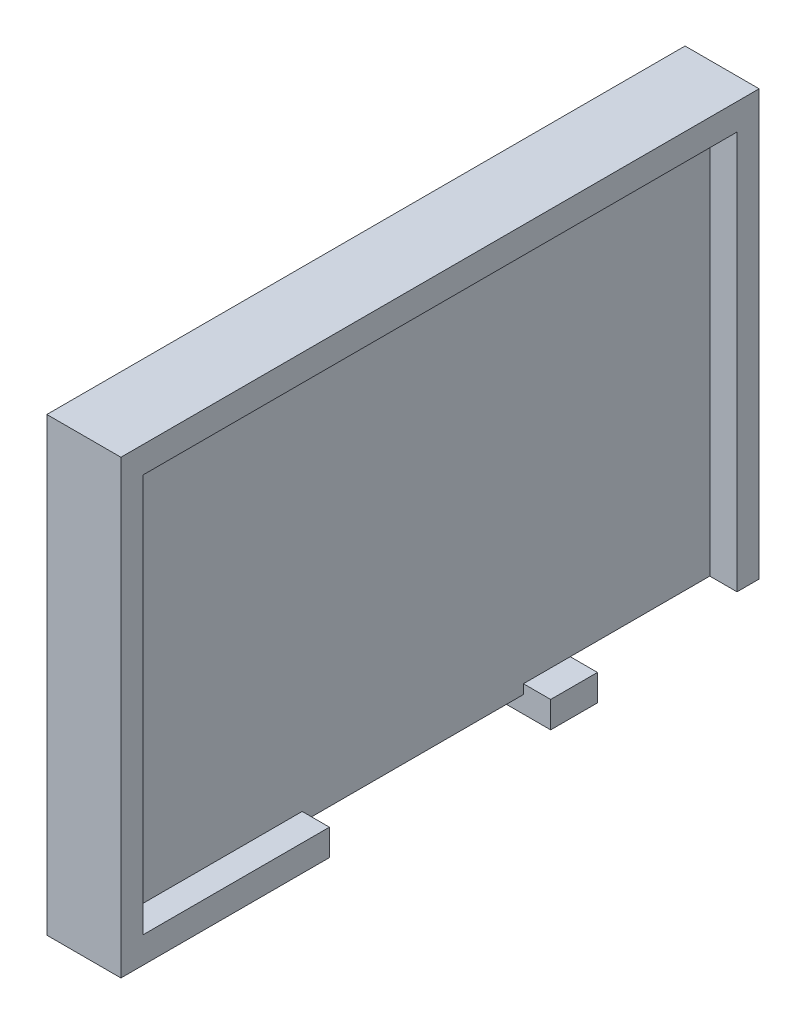
from build123d import *

# Parameters (mm, degrees)
SKETCH1_W           = 26.5
SKETCH1_H           = 37.5
BOSS_EXTRUDE1_DEPTH = 4.353
SKETCH2_W           = 23.4
SKETCH2_H           = 34.9
CUT_EXTRUDE1_DEPTH  = 1.6
SKETCH3_W           = 1.55
SKETCH3_H           = 13
CUT_EXTRUDE2_DEPTH  = 1.6
SKETCH4_W           = 2.753
SKETCH4_H           = 13
CUT_EXTRUDE3_DEPTH  = 1
SKETCH5_W           = 1.55
SKETCH5_H           = 9.5
CUT_EXTRUDE5_DEPTH  = 1.6
CUT_EXTRUDE6_DEPTH  = 9.5
SKETCH7_W           = 4.587747781
SKETCH7_H           = 26.668615153
SKETCH7_W_2         = 9.921470812
SKETCH7_H_2         = 17.49311959
CUT_EXTRUDE7_DEPTH  = 2
SKETCH8_W           = 1.6
SKETCH8_H           = 3.8
BOSS_EXTRUDE2_DEPTH = 1.6


with BuildPart() as part:
    # Sketch1 → Boss-Extrude1 (new body)
    with BuildSketch(Plane.YZ):
        with Locations((57.87, 107.93)):
            Rectangle(SKETCH1_W, SKETCH1_H)
    extrude(amount=BOSS_EXTRUDE1_DEPTH)

    # Sketch2 → Cut-Extrude1 (cut)
    with BuildSketch(Plane.YZ.offset(4.353)):
        with Locations((57.87, 107.93)):
            Rectangle(SKETCH2_W, SKETCH2_H)
    extrude(amount=-CUT_EXTRUDE1_DEPTH, mode=Mode.SUBTRACT)

    # Sketch3 → Cut-Extrude2 (cut)
    with BuildSketch(Plane.YZ.offset(4.353)):
        with Locations((45.395, 107.93)):
            Rectangle(SKETCH3_W, SKETCH3_H)
    extrude(amount=-CUT_EXTRUDE2_DEPTH, mode=Mode.SUBTRACT)

    # Sketch4 → Cut-Extrude3 (cut)
    with BuildSketch(Plane.XZ.offset(-44.62)):
        with Locations((1.3765, 107.93)):
            Rectangle(SKETCH4_W, SKETCH4_H)
    extrude(amount=-CUT_EXTRUDE3_DEPTH, mode=Mode.SUBTRACT)

    # Sketch5 → Cut-Extrude5 (cut)
    with BuildSketch(Plane.YZ.offset(4.353)):
        with Locations((45.395, 93.93)):
            Rectangle(SKETCH5_W, SKETCH5_H)
    extrude(amount=-CUT_EXTRUDE5_DEPTH, mode=Mode.SUBTRACT)

    # Sketch6 → Cut-Extrude6 (cut)
    with BuildSketch(Plane(origin=(0, 0, 89.18), x_dir=(1, 0, 0), z_dir=(0, 0, -1))):
        Polygon((1.953, -46.17), (2.753, -46.17), (2.753, -44.62), (0, -44.62), (0, -49.12), (1.953, -49.12), align=None)
    extrude(amount=-CUT_EXTRUDE6_DEPTH, mode=Mode.SUBTRACT)

    # Sketch7 → Cut-Extrude7 (cut)
    with BuildSketch(Plane(origin=(0, 0, 0), x_dir=(0, -1, 0), z_dir=(-1, 0, 0))):
        with Locations((-52.536232928, 109.172253496)):
            Rectangle(SKETCH7_W, SKETCH7_H)
        Polygon((-57.329123903, 95.837945919), (-57.329123903, 90.653417938), (-49.12, 90.653417938), (-49.12, 95.837945919), (-50.242359038, 95.837945919), (-54.830106819, 95.837945919), align=None)
        with Locations((-61.879572923, 107.531107948)):
            Rectangle(SKETCH7_W_2, SKETCH7_H_2)
    extrude(amount=-CUT_EXTRUDE7_DEPTH, mode=Mode.SUBTRACT)

    # Sketch8 → Boss-Extrude2 (add)
    with BuildSketch(Plane(origin=(0, 0, 0), x_dir=(0, -1, 0), z_dir=(-1, 0, 0))):
        with Locations((-68.22, 123.18)):
            Rectangle(SKETCH8_W, SKETCH8_H)
    boss_extrude2 = extrude(amount=BOSS_EXTRUDE2_DEPTH)

    # Mirror1: Boss-Extrude2 across plane
    add(boss_extrude2.mirror(Plane(origin=(0, 0, 107.93), x_dir=(1, 0, 0), z_dir=(0, 0, -1))))

    # Mirror2: Boss-Extrude2 across plane
    add(boss_extrude2.mirror(Plane(origin=(0, 57.62, 0), x_dir=(0, 0, 1), z_dir=(0, -1, 0))))


solid = part.part
